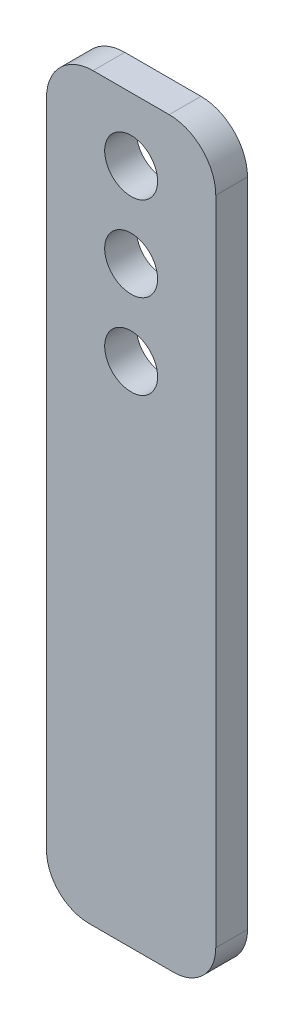
from build123d import *

# Parameters (mm, degrees)
ESQUISSE1_R        = 12.5
BOSS_EXTRU_1_DEPTH = 15


with BuildPart() as part:
    # Esquisse1 → Boss.-Extru.1 (new body)
    with BuildSketch(Plane.XY):
        with BuildLine():
            Line((-20, -350), (20, -350))
            ThreePointArc((20, -350), (34.142135624, -344.142135624), (40, -330))
            Line((40, -330), (40, -22))
            ThreePointArc((40, -22), (33.556349186, -6.443650814), (18, 0))
            Line((18, 0), (-18, 0))
            ThreePointArc((-18, 0), (-33.556349186, -6.443650814), (-40, -22))
            Line((-40, -22), (-40, -330))
            ThreePointArc((-40, -330), (-34.142135624, -344.142135624), (-20, -350))
        make_face()
        with Locations((0, -30)):
            Circle(ESQUISSE1_R, mode=Mode.SUBTRACT)
        with Locations((0, -70)):
            Circle(ESQUISSE1_R, mode=Mode.SUBTRACT)
        with Locations((0, -110)):
            Circle(ESQUISSE1_R, mode=Mode.SUBTRACT)
    extrude(amount=BOSS_EXTRU_1_DEPTH)


solid = part.part
